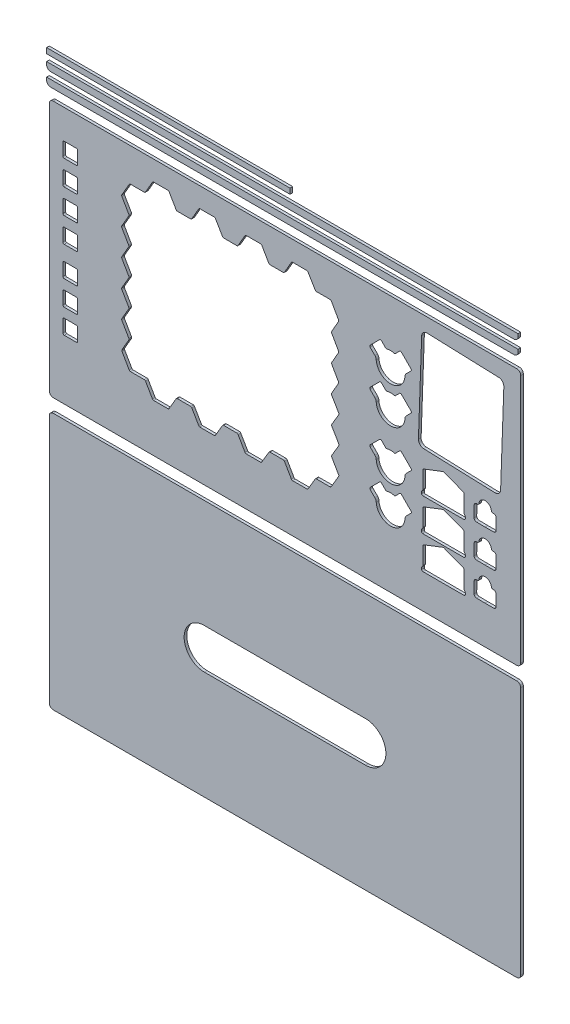
from build123d import *

# Parameters (mm, degrees)
SKETCH_1_W             = 350.5
SKETCH_1_H             = 191
SKETCH_1_W_2           = 11
SKETCH_1_H_2           = 11
EXTRUDE_1_DEPTH        = 2
FILLET_1_R             = 3
FILLET_2_R             = 1
FILLET_3_R             = 1
SKETCH_3_W             = 350.5
SKETCH_3_H             = 5
EXTRUDE_2_DEPTH        = 2
FILLET_4_R             = 3
PATTERN_LINEAR_1_COUNT = 2
PATTERN_LINEAR_1_PITCH = 10
SKETCH_6_W             = 181
SKETCH_6_H             = 4
EXTRUDE_4_DEPTH        = 2
SKETCH_7_W             = 350.5
SKETCH_7_H             = 191
EXTRUDE_5_DEPTH        = 2
FILLET_5_R             = 3
CUT_EXTRUDE_1_DEPTH    = 2
FILLET_6_R             = 4


with BuildPart() as part:
    # 草图1 (on Front Plane) → 凸台-拉伸1 (new body)
    with BuildSketch(Plane.XY):
        with Locations((170.25, 90)):
            Rectangle(SKETCH_1_W, SKETCH_1_H)
        Polygon((72.008304604, 170.7), (83.774537021, 170.7), (89.61625302, 160.684401711), (100.628787662, 160.684401711), (106.411296031, 170.7), (118.23575241, 170.7), (124.077468409, 160.684401711), (135.040913001, 160.684401711), (140.823421369, 170.7), (152.686360601, 170.7), (158.5280766, 160.684401711), (169.523402832, 160.684401711), (175.3059112, 170.7), (187.041301816, 170.7), (192.989498068, 160.684401711), (204.383267385, 160.684401711), (210.347623822, 150.164149811), (204.638118153, 140.166389824), (210.347623822, 130.095657383), (204.684656519, 120.179389462), (210.293074804, 110.286960373), (204.571821609, 100.268629611), (210.521640659, 90.250298849), (204.684656519, 80.289856755), (210.570829862, 70.378692907), (204.684656519, 60.334312567), (210.425234792, 50.438079514), (204.331581115, 40.039647183), (192.989498068, 40.039647183), (187.14778207, 30.071130471), (175.3059112, 30.071130471), (169.523402832, 40.039647183), (158.5280766, 40.039647183), (152.686360601, 30.071130471), (140.823421369, 30.071130471), (135.040913001, 40.039647183), (124.077468409, 40.039647183), (118.23575241, 30.071130471), (106.411296031, 30.071130471), (100.628787662, 40.039647183), (89.61625302, 40.039647183), (83.774537021, 30.071130471), (72.008304604, 30.071130471), (66.225796236, 40.039647183), (54.731284746, 40.039647183), (48.72774704, 50.438079514), (54.441339858, 60.334312567), (48.642214164, 70.378692907), (54.36442728, 80.289856755), (48.613763355, 90.250298849), (54.397849318, 100.268629611), (48.613763355, 110.286960373), (54.325159953, 120.179389462), (48.6, 130.095657383), (54.414340086, 140.166389824), (48.649772573, 150.150913639), (54.731284746, 160.684401711), (66.225796236, 160.684401711), align=None, mode=Mode.SUBTRACT)
        with Locations((10.610326311, 158.213048945)):
            Rectangle(SKETCH_1_W_2, SKETCH_1_H_2, mode=Mode.SUBTRACT)
        with Locations((10.610326311, 139.763048945)):
            Rectangle(SKETCH_1_W_2, SKETCH_1_H_2, mode=Mode.SUBTRACT)
        with Locations((10.610326311, 121.313048945)):
            Rectangle(SKETCH_1_W_2, SKETCH_1_H_2, mode=Mode.SUBTRACT)
        with Locations((10.610326311, 102.863048945)):
            Rectangle(SKETCH_1_W_2, SKETCH_1_H_2, mode=Mode.SUBTRACT)
        with Locations((10.610326311, 80.717507942)):
            Rectangle(SKETCH_1_W_2, SKETCH_1_H_2, mode=Mode.SUBTRACT)
        with Locations((10.610326311, 62.358921806)):
            Rectangle(SKETCH_1_W_2, SKETCH_1_H_2, mode=Mode.SUBTRACT)
        with Locations((10.610326311, 44.297250493)):
            Rectangle(SKETCH_1_W_2, SKETCH_1_H_2, mode=Mode.SUBTRACT)
        with BuildLine():
            Line((264.633583841, 145.422653329), (256.139956266, 153.916280905))
            Line((256.139956266, 153.916280905), (251.951948449, 149.728273088))
            ThreePointArc((251.951948449, 149.728273088), (248.709503555, 150.253763412), (245.467058661, 149.728273088))
            Line((245.467058661, 149.728273088), (241.290747298, 153.904584451))
            Line((241.290747298, 153.904584451), (232.869120036, 145.482957189))
            Line((232.869120036, 145.482957189), (237.065814909, 141.286262317))
            ThreePointArc((237.065814909, 141.286262317), (237.808745503, 140.174304334), (238.069504679, 138.862663729))
            ThreePointArc((238.069504679, 138.862663729), (248.750420673, 128.88359772), (259.431336666, 138.862663729))
            ThreePointArc((259.431336666, 138.862663729), (259.736815506, 140.174491211), (260.497192829, 141.286262317))
            Line((260.497192829, 141.286262317), (264.633583841, 145.422653329))
        make_face(mode=Mode.SUBTRACT)
        with BuildLine():
            Line((264.633583841, 81.245887811), (256.139956266, 89.739515386))
            Line((256.139956266, 89.739515386), (251.951948449, 85.551507569))
            ThreePointArc((251.951948449, 85.551507569), (248.709503555, 86.076997893), (245.467058661, 85.551507569))
            Line((245.467058661, 85.551507569), (241.290747298, 89.727818932))
            Line((241.290747298, 89.727818932), (232.869120036, 81.306191671))
            Line((232.869120036, 81.306191671), (237.065814909, 77.109496799))
            ThreePointArc((237.065814909, 77.109496799), (237.808745503, 75.997538815), (238.069504679, 74.68589821))
            ThreePointArc((238.069504679, 74.68589821), (248.750420673, 64.706832202), (259.431336666, 74.68589821))
            ThreePointArc((259.431336666, 74.68589821), (259.736815506, 75.997725692), (260.497192829, 77.109496799))
            Line((260.497192829, 77.109496799), (264.633583841, 81.245887811))
        make_face(mode=Mode.SUBTRACT)
        with BuildLine():
            Line((264.633583841, 118.30250483), (256.139956266, 126.796132406))
            Line((256.139956266, 126.796132406), (251.951948449, 122.608124589))
            ThreePointArc((251.951948449, 122.608124589), (248.709503555, 123.133614913), (245.467058661, 122.608124589))
            Line((245.467058661, 122.608124589), (241.290747298, 126.784435952))
            Line((241.290747298, 126.784435952), (232.869120036, 118.36280869))
            Line((232.869120036, 118.36280869), (237.065814909, 114.166113818))
            ThreePointArc((237.065814909, 114.166113818), (237.808745503, 113.054155835), (238.069504679, 111.74251523))
            ThreePointArc((238.069504679, 111.74251523), (248.750420673, 101.763449221), (259.431336666, 111.74251523))
            ThreePointArc((259.431336666, 111.74251523), (259.736815506, 113.054342712), (260.497192829, 114.166113818))
            Line((260.497192829, 114.166113818), (264.633583841, 118.30250483))
        make_face(mode=Mode.SUBTRACT)
        with BuildLine():
            Line((264.633583841, 53.829272234), (256.139956266, 62.322899809))
            Line((256.139956266, 62.322899809), (251.951948449, 58.134891992))
            ThreePointArc((251.951948449, 58.134891992), (248.709503555, 58.660382317), (245.467058661, 58.134891992))
            Line((245.467058661, 58.134891992), (241.290747298, 62.311203356))
            Line((241.290747298, 62.311203356), (232.869120036, 53.889576094))
            Line((232.869120036, 53.889576094), (237.065814909, 49.692881222))
            ThreePointArc((237.065814909, 49.692881222), (237.808745503, 48.580923239), (238.069504679, 47.269282633))
            ThreePointArc((238.069504679, 47.269282633), (248.750420673, 37.290216625), (259.431336666, 47.269282633))
            ThreePointArc((259.431336666, 47.269282633), (259.736815506, 48.581110116), (260.497192829, 49.692881222))
            Line((260.497192829, 49.692881222), (264.633583841, 53.829272234))
        make_face(mode=Mode.SUBTRACT)
        Polygon((303.339019722, 37.287555494), (288.04391136, 43.178839965), (272.748802999, 37.287555494), (272.748802999, 23.705199379), (271.789506555, 22.493401289), (271.789506555, 19.959602308), (304.298316165, 19.959602308), (304.298316165, 22.493401289), (303.339019722, 23.705199379), align=None, mode=Mode.SUBTRACT)
        Polygon((272.748802999, 61.687555494), (288.04391136, 67.578839965), (303.339019722, 61.687555494), (303.339019722, 48.105199379), (304.298316165, 46.893401289), (304.298316165, 44.359602308), (271.789506555, 44.359602308), (271.789506555, 46.893401289), (272.748802999, 48.105199379), align=None, mode=Mode.SUBTRACT)
        Polygon((272.748802999, 86.087555494), (288.04391136, 91.978839965), (303.339019722, 86.087555494), (303.339019722, 72.505199379), (304.298316165, 71.293401289), (304.298316165, 68.759602308), (271.789506555, 68.759602308), (271.789506555, 71.293401289), (272.748802999, 72.505199379), align=None, mode=Mode.SUBTRACT)
        with BuildLine():
            Line((318.988108742, 71.773531009), (325.392466248, 71.773531009))
            ThreePointArc((325.392466248, 71.773531009), (326.665258454, 72.300738803), (327.192466248, 73.573531009))
            Line((327.192466248, 73.573531009), (327.192466248, 81.815541728))
            ThreePointArc((327.192466248, 81.815541728), (326.665258454, 83.088333934), (325.392466248, 83.615541728))
            Line((325.392466248, 83.615541728), (323.658370706, 83.615541728))
            ThreePointArc((323.658370706, 83.615541728), (319.069740454, 88.773335015), (314.431788323, 83.659847045))
            Line((314.431788323, 83.659847045), (312.69777275, 83.67650064))
            ThreePointArc((312.69777275, 83.67650064), (311.419976137, 83.161540572), (310.880569243, 81.893870165))
            Line((310.880569243, 81.893870165), (310.801416103, 73.652239533))
            ThreePointArc((310.801416103, 73.652239533), (311.316376171, 72.374442919), (312.584046578, 71.835036025))
            Line((312.584046578, 71.835036025), (318.988108742, 71.773531009))
        make_face(mode=Mode.SUBTRACT)
        with BuildLine():
            Line((325.392466248, 59.115541728), (323.658370706, 59.115541728))
            ThreePointArc((323.658370706, 59.115541728), (319.069740454, 64.273335015), (314.431788323, 59.159847045))
            Line((314.431788323, 59.159847045), (312.69777275, 59.17650064))
            ThreePointArc((312.69777275, 59.17650064), (311.419976137, 58.661540572), (310.880569243, 57.393870165))
            Line((310.880569243, 57.393870165), (310.801416103, 49.152239533))
            ThreePointArc((310.801416103, 49.152239533), (311.316376171, 47.874442919), (312.584046578, 47.335036025))
            Line((312.584046578, 47.335036025), (318.988108742, 47.273531009))
            Line((318.988108742, 47.273531009), (325.392466248, 47.273531009))
            ThreePointArc((325.392466248, 47.273531009), (326.665258454, 47.800738803), (327.192466248, 49.073531009))
            Line((327.192466248, 49.073531009), (327.192466248, 57.315541728))
            ThreePointArc((327.192466248, 57.315541728), (326.665258454, 58.588333934), (325.392466248, 59.115541728))
        make_face(mode=Mode.SUBTRACT)
        with BuildLine():
            Line((325.392466248, 34.615541728), (323.658370706, 34.615541728))
            ThreePointArc((323.658370706, 34.615541728), (319.069740454, 39.773335015), (314.431788323, 34.659847045))
            Line((314.431788323, 34.659847045), (312.69777275, 34.67650064))
            ThreePointArc((312.69777275, 34.67650064), (311.419976137, 34.161540572), (310.880569243, 32.893870165))
            Line((310.880569243, 32.893870165), (310.801416103, 24.652239533))
            ThreePointArc((310.801416103, 24.652239533), (311.316376171, 23.374442919), (312.584046578, 22.835036025))
            Line((312.584046578, 22.835036025), (318.988108742, 22.773531009))
            Line((318.988108742, 22.773531009), (325.392466248, 22.773531009))
            ThreePointArc((325.392466248, 22.773531009), (326.665258454, 23.300738803), (327.192466248, 24.573531009))
            Line((327.192466248, 24.573531009), (327.192466248, 32.815541728))
            ThreePointArc((327.192466248, 32.815541728), (326.665258454, 34.088333934), (325.392466248, 34.615541728))
        make_face(mode=Mode.SUBTRACT)
        Polygon((271.993130723, 175.234480342), (333.093195933, 173.073222372), (330.4163794, 97.398005919), (269.31631419, 99.559263889), align=None, mode=Mode.SUBTRACT)
    extrude(amount=-EXTRUDE_1_DEPTH)

    # 圆角1
    fillet_1_edges = [part.edges().sort_by_distance(p)[0] for p in [
        (345.5, 185.5, -1),
        (345.5, -5.5, -1),
        (-5, -5.5, -1),
        (-5, 185.5, -1),
    ]]
    fillet(fillet_1_edges, radius=FILLET_1_R)

    # 圆角2
    fillet_2_edges = [part.edges().sort_by_distance(p)[0] for p in [
        (66.225796236, 160.684401711, -1),
        (72.008304604, 170.7, -1),
        (83.774537021, 170.7, -1),
        (89.61625302, 160.684401711, -1),
        (100.628787662, 160.684401711, -1),
        (106.411296031, 170.7, -1),
        (118.23575241, 170.7, -1),
        (124.077468409, 160.684401711, -1),
        (135.040913001, 160.684401711, -1),
        (140.823421369, 170.7, -1),
        (152.686360601, 170.7, -1),
        (158.5280766, 160.684401711, -1),
        (169.523402832, 160.684401711, -1),
        (175.3059112, 170.7, -1),
        (187.041301816, 170.7, -1),
        (192.989498068, 160.684401711, -1),
        (204.383267385, 160.684401711, -1),
        (210.347623822, 150.164149811, -1),
        (204.638118153, 140.166389824, -1),
        (210.347623822, 130.095657383, -1),
        (204.684656519, 120.179389462, -1),
        (210.293074804, 110.286960373, -1),
        (204.571821609, 100.268629611, -1),
        (210.521640659, 90.250298849, -1),
        (204.684656519, 80.289856755, -1),
        (210.570829862, 70.378692907, -1),
        (204.684656519, 60.334312567, -1),
        (210.425234792, 50.438079514, -1),
        (204.331581115, 40.039647183, -1),
        (192.989498068, 40.039647183, -1),
        (187.14778207, 30.071130471, -1),
        (175.3059112, 30.071130471, -1),
        (169.523402832, 40.039647183, -1),
        (158.5280766, 40.039647183, -1),
        (152.686360601, 30.071130471, -1),
        (140.823421369, 30.071130471, -1),
        (135.040913001, 40.039647183, -1),
        (124.077468409, 40.039647183, -1),
        (118.23575241, 30.071130471, -1),
        (106.411296031, 30.071130471, -1),
        (100.628787662, 40.039647183, -1),
        (89.61625302, 40.039647183, -1),
        (83.774537021, 30.071130471, -1),
        (72.008304604, 30.071130471, -1),
        (66.225796236, 40.039647183, -1),
        (54.731284746, 40.039647183, -1),
        (48.72774704, 50.438079514, -1),
        (54.441339858, 60.334312567, -1),
        (48.642214164, 70.378692907, -1),
        (54.36442728, 80.289856755, -1),
        (48.613763355, 90.250298849, -1),
        (54.397849318, 100.268629611, -1),
        (48.613763355, 110.286960373, -1),
        (54.325159953, 120.179389462, -1),
        (48.6, 130.095657383, -1),
        (54.414340086, 140.166389824, -1),
        (48.649772573, 150.150913639, -1),
        (54.731284746, 160.684401711, -1),
    ]]
    fillet(fillet_2_edges, radius=FILLET_2_R)

    # 圆角3
    fillet_3_edges = [part.edges().sort_by_distance(p)[0] for p in [
        (5.110326311, 152.713048945, -1),
        (5.110326311, 163.713048945, -1),
        (16.110326311, 163.713048945, -1),
        (16.110326311, 152.713048945, -1),
        (5.110326311, 75.217507942, -1),
        (5.110326311, 86.217507942, -1),
        (16.110326311, 86.217507942, -1),
        (16.110326311, 75.217507942, -1),
        (5.110326311, 134.263048945, -1),
        (5.110326311, 145.263048945, -1),
        (16.110326311, 145.263048945, -1),
        (16.110326311, 134.263048945, -1),
        (5.110326311, 115.813048945, -1),
        (5.110326311, 126.813048945, -1),
        (16.110326311, 126.813048945, -1),
        (16.110326311, 115.813048945, -1),
        (5.110326311, 97.363048945, -1),
        (5.110326311, 108.363048945, -1),
        (16.110326311, 108.363048945, -1),
        (16.110326311, 97.363048945, -1),
        (5.110326311, 56.858921806, -1),
        (5.110326311, 67.858921806, -1),
        (16.110326311, 67.858921806, -1),
        (16.110326311, 56.858921806, -1),
        (5.110326311, 38.797250493, -1),
        (5.110326311, 49.797250493, -1),
        (16.110326311, 49.797250493, -1),
        (16.110326311, 38.797250493, -1),
        (264.633583841, 145.422653329, -1),
        (259.431336666, 138.862663729, -1),
        (238.069504679, 138.862663729, -1),
        (232.869120036, 145.482957189, -1),
        (241.290747298, 153.904584451, -1),
        (245.467058661, 149.728273088, -1),
        (251.951948449, 149.728273088, -1),
        (256.139956266, 153.916280905, -1),
        (264.633583841, 81.245887811, -1),
        (259.431336666, 74.68589821, -1),
        (238.069504679, 74.68589821, -1),
        (232.869120036, 81.306191671, -1),
        (241.290747298, 89.727818932, -1),
        (245.467058661, 85.551507569, -1),
        (251.951948449, 85.551507569, -1),
        (256.139956266, 89.739515386, -1),
        (264.633583841, 118.30250483, -1),
        (259.431336666, 111.74251523, -1),
        (238.069504679, 111.74251523, -1),
        (232.869120036, 118.36280869, -1),
        (241.290747298, 126.784435952, -1),
        (245.467058661, 122.608124589, -1),
        (251.951948449, 122.608124589, -1),
        (256.139956266, 126.796132406, -1),
        (264.633583841, 53.829272234, -1),
        (259.431336666, 47.269282633, -1),
        (238.069504679, 47.269282633, -1),
        (232.869120036, 53.889576094, -1),
        (241.290747298, 62.311203356, -1),
        (245.467058661, 58.134891992, -1),
        (251.951948449, 58.134891992, -1),
        (256.139956266, 62.322899809, -1),
        (318.988108742, 71.773531009, -1),
        (314.431788323, 83.659847045, -1),
        (323.658370706, 83.615541728, -1),
        (303.339019722, 61.687555494, -1),
        (303.339019722, 48.105199379, -1),
        (304.298316165, 46.893401289, -1),
        (304.298316165, 44.359602308, -1),
        (271.789506555, 44.359602308, -1),
        (271.789506555, 46.893401289, -1),
        (272.748802999, 48.105199379, -1),
        (272.748802999, 61.687555494, -1),
        (288.04391136, 67.578839965, -1),
        (303.339019722, 37.287555494, -1),
        (303.339019722, 23.705199379, -1),
        (304.298316165, 22.493401289, -1),
        (304.298316165, 19.959602308, -1),
        (271.789506555, 19.959602308, -1),
        (271.789506555, 22.493401289, -1),
        (272.748802999, 23.705199379, -1),
        (272.748802999, 37.287555494, -1),
        (288.04391136, 43.178839965, -1),
        (303.339019722, 86.087555494, -1),
        (303.339019722, 72.505199379, -1),
        (304.298316165, 71.293401289, -1),
        (304.298316165, 68.759602308, -1),
        (271.789506555, 68.759602308, -1),
        (271.789506555, 71.293401289, -1),
        (272.748802999, 72.505199379, -1),
        (272.748802999, 86.087555494, -1),
        (288.04391136, 91.978839965, -1),
        (318.988108742, 47.273531009, -1),
        (314.431788323, 59.159847045, -1),
        (323.658370706, 59.115541728, -1),
        (318.988108742, 22.773531009, -1),
        (314.431788323, 34.659847045, -1),
        (323.658370706, 34.615541728, -1),
    ]]
    fillet(fillet_3_edges, radius=FILLET_3_R)

    # 圆角6
    fillet_6_edges = [part.edges().sort_by_distance(p)[0] for p in [
        (269.31631419, 99.559263889, -1),
        (271.993130723, 175.234480342, -1),
        (333.093195933, 173.073222372, -1),
        (330.4163794, 97.398005919, -1),
    ]]
    fillet(fillet_6_edges, radius=FILLET_6_R)


with BuildPart() as body_2:
    # 草图3 → 凸台-拉伸2 (new body)
    with BuildSketch(Plane.XY):
        with Locations((170.25, 198)):
            Rectangle(SKETCH_3_W, SKETCH_3_H)
    extrude(amount=EXTRUDE_2_DEPTH)

    # 圆角4
    fillet_4_edges = [body_2.edges().sort_by_distance(p)[0] for p in [
        (345.5, 195.5, 1),
        (-5, 195.5, 1),
    ]]
    fillet(fillet_4_edges, radius=FILLET_4_R)


with BuildPart() as pattern_linear_1_1:
    # 阵列(线性)1: pattern copy
    add(body_2.part.moved(Location(Vector(0, 1, 0) * (1 * PATTERN_LINEAR_1_PITCH))))


with BuildPart() as body_4:
    # 草图6 → 凸台-拉伸4 (new body)
    with BuildSketch(Plane.XY):
        with Locations((85.5, 217.5)):
            Rectangle(SKETCH_6_W, SKETCH_6_H)
    extrude(amount=EXTRUDE_4_DEPTH)


with BuildPart() as body_5:
    # 草图7 → 凸台-拉伸5 (new body)
    with BuildSketch(Plane.XY):
        with Locations((170.25, -111)):
            Rectangle(SKETCH_7_W, SKETCH_7_H)
    extrude(amount=-EXTRUDE_5_DEPTH)

    # 圆角5
    fillet_5_edges = [body_5.edges().sort_by_distance(p)[0] for p in [
        (-5, -15.5, -1),
        (345.5, -15.5, -1),
        (345.5, -206.5, -1),
        (-5, -206.5, -1),
    ]]
    fillet(fillet_5_edges, radius=FILLET_5_R)

    # 草图8 → 切除-拉伸1 (cut)
    with BuildSketch(Plane.XY):
        with BuildLine():
            Line((110.25, -96), (230.25, -96))
            ThreePointArc((230.25, -96), (245.25, -111), (230.25, -126))
            Line((230.25, -126), (110.25, -126))
            ThreePointArc((110.25, -126), (95.25, -111), (110.25, -96))
        make_face()
    extrude(amount=-CUT_EXTRUDE_1_DEPTH, mode=Mode.SUBTRACT)


solid = Compound([part.part, body_2.part, pattern_linear_1_1.part, body_4.part, body_5.part])
